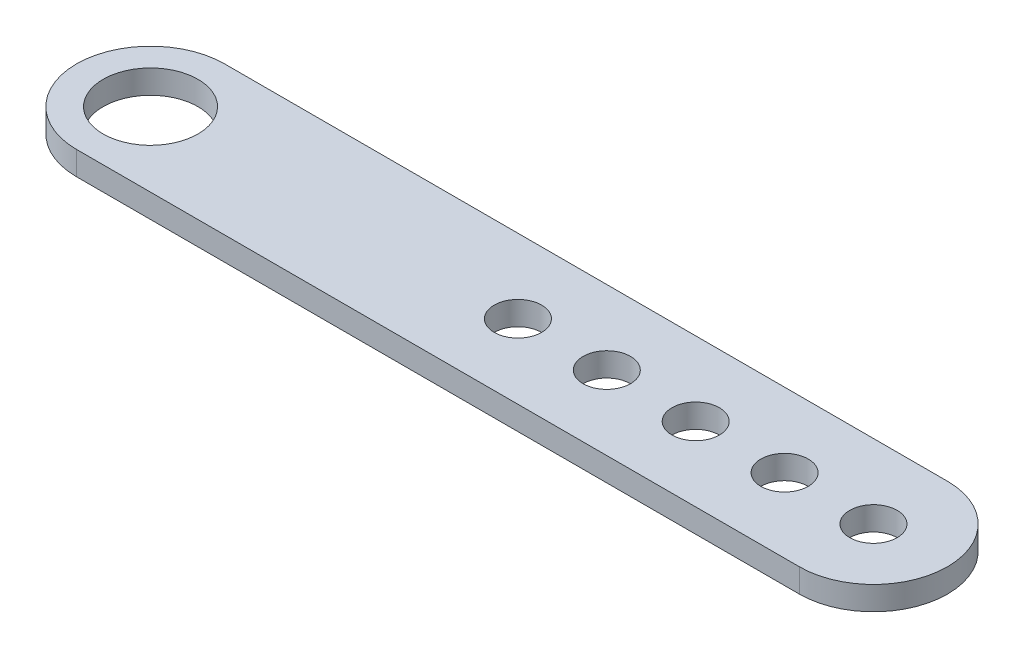
from build123d import *

# Parameters (mm, degrees)
SKETCH1_R           = 8
SKETCH1_R_2         = 4
BOSS_EXTRUDE1_DEPTH = 2


with BuildPart() as part:
    # Sketch1 → Boss-Extrude1 (new body, symmetric)
    with BuildSketch(Plane(origin=(0, 0, 0), x_dir=(1, 0, 0), z_dir=(0, 1, 0))):
        with BuildLine():
            Line((-61, 12.5), (61, 12.5))
            ThreePointArc((61, 12.5), (73.5, 0), (61, -12.5))
            Line((61, -12.5), (-61, -12.5))
            ThreePointArc((-61, -12.5), (-73.5, 0), (-61, 12.5))
        make_face()
        with Locations((-61, 0)):
            Circle(SKETCH1_R, mode=Mode.SUBTRACT)
        with Locations((1, 0)):
            Circle(SKETCH1_R_2, mode=Mode.SUBTRACT)
        with Locations((16, 0)):
            Circle(SKETCH1_R_2, mode=Mode.SUBTRACT)
        with Locations((31, 0)):
            Circle(SKETCH1_R_2, mode=Mode.SUBTRACT)
        with Locations((46, 0)):
            Circle(SKETCH1_R_2, mode=Mode.SUBTRACT)
        with Locations((61, 0)):
            Circle(SKETCH1_R_2, mode=Mode.SUBTRACT)
    extrude(amount=BOSS_EXTRUDE1_DEPTH, both=True)


solid = part.part
